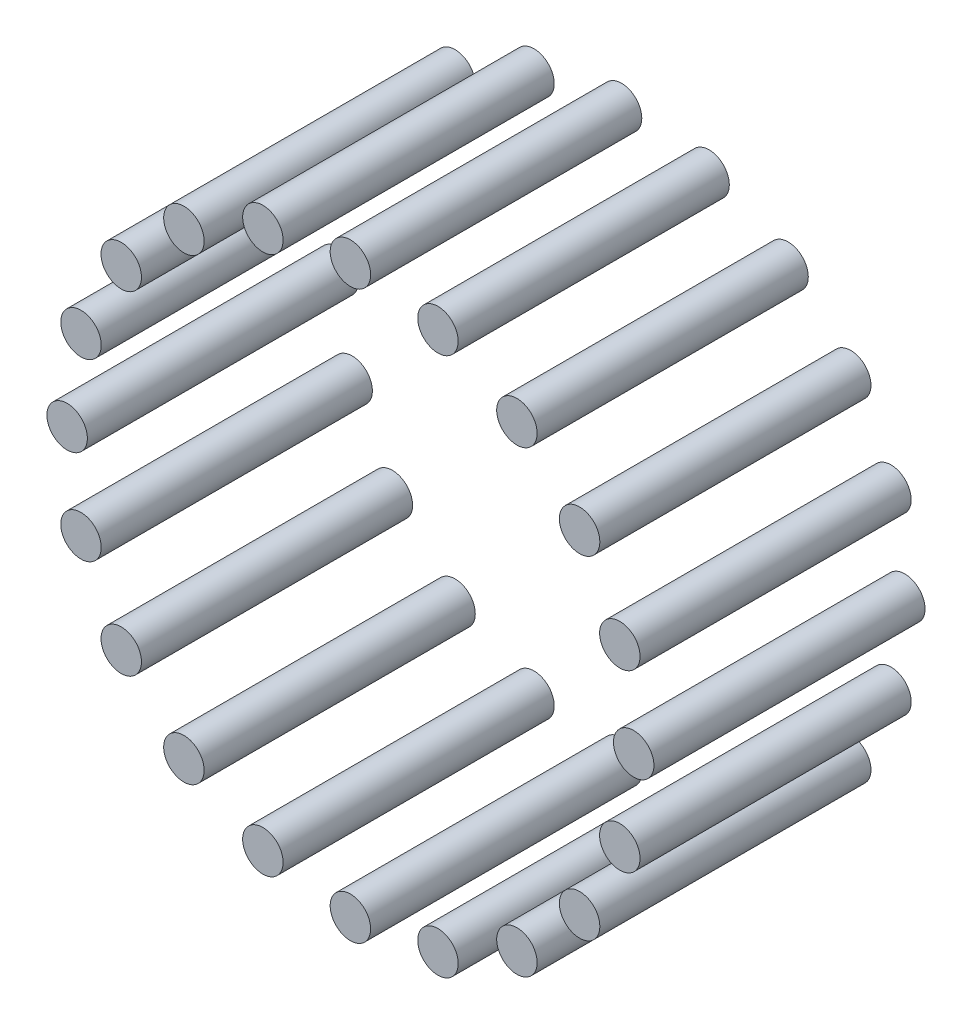
from build123d import *

# Parameters (mm, degrees)
SKETCH1_R              = 2.5
BOSS_EXTRUDE1_DEPTH    = 33.5
BOSS_EXTRUDE1_2_DEPTH  = 33.5
BOSS_EXTRUDE1_3_DEPTH  = 33.5
BOSS_EXTRUDE1_4_DEPTH  = 33.5
BOSS_EXTRUDE1_5_DEPTH  = 33.5
BOSS_EXTRUDE1_6_DEPTH  = 33.5
BOSS_EXTRUDE1_7_DEPTH  = 33.5
BOSS_EXTRUDE1_8_DEPTH  = 33.5
BOSS_EXTRUDE1_9_DEPTH  = 33.5
BOSS_EXTRUDE1_10_DEPTH = 33.5
BOSS_EXTRUDE1_11_DEPTH = 33.5
BOSS_EXTRUDE1_12_DEPTH = 33.5
BOSS_EXTRUDE1_13_DEPTH = 33.5
BOSS_EXTRUDE1_14_DEPTH = 33.5
BOSS_EXTRUDE1_15_DEPTH = 33.5
BOSS_EXTRUDE1_16_DEPTH = 33.5
BOSS_EXTRUDE1_17_DEPTH = 33.5
BOSS_EXTRUDE1_18_DEPTH = 33.5
BOSS_EXTRUDE1_19_DEPTH = 33.5
BOSS_EXTRUDE1_20_DEPTH = 33.5


with BuildPart() as part:
    # Sketch1 → Boss-Extrude1 (new body)
    with BuildSketch(Plane.XY):
        with Locations((0, 35)):
            Circle(SKETCH1_R)
    extrude(amount=BOSS_EXTRUDE1_DEPTH)


with BuildPart() as body_2:
    # Sketch1 → Boss-Extrude1 2 (new body)
    with BuildSketch(Plane.XY):
        with Locations((10.815594803, 33.28697807)):
            Circle(SKETCH1_R)
    extrude(amount=BOSS_EXTRUDE1_2_DEPTH)


with BuildPart() as body_3:
    # Sketch1 → Boss-Extrude1 3 (new body)
    with BuildSketch(Plane.XY):
        with Locations((20.57248383, 28.315594803)):
            Circle(SKETCH1_R)
    extrude(amount=BOSS_EXTRUDE1_3_DEPTH)


with BuildPart() as body_4:
    # Sketch1 → Boss-Extrude1 4 (new body)
    with BuildSketch(Plane.XY):
        with Locations((28.315594803, 20.57248383)):
            Circle(SKETCH1_R)
    extrude(amount=BOSS_EXTRUDE1_4_DEPTH)


with BuildPart() as body_5:
    # Sketch1 → Boss-Extrude1 5 (new body)
    with BuildSketch(Plane.XY):
        with Locations((33.28697807, 10.815594803)):
            Circle(SKETCH1_R)
    extrude(amount=BOSS_EXTRUDE1_5_DEPTH)


with BuildPart() as body_6:
    # Sketch1 → Boss-Extrude1 6 (new body)
    with BuildSketch(Plane.XY):
        with Locations((35, 0)):
            Circle(SKETCH1_R)
    extrude(amount=BOSS_EXTRUDE1_6_DEPTH)


with BuildPart() as body_7:
    # Sketch1 → Boss-Extrude1 7 (new body)
    with BuildSketch(Plane.XY):
        with Locations((33.28697807, -10.815594803)):
            Circle(SKETCH1_R)
    extrude(amount=BOSS_EXTRUDE1_7_DEPTH)


with BuildPart() as body_8:
    # Sketch1 → Boss-Extrude1 8 (new body)
    with BuildSketch(Plane.XY):
        with Locations((28.315594803, -20.57248383)):
            Circle(SKETCH1_R)
    extrude(amount=BOSS_EXTRUDE1_8_DEPTH)


with BuildPart() as body_9:
    # Sketch1 → Boss-Extrude1 9 (new body)
    with BuildSketch(Plane.XY):
        with Locations((20.57248383, -28.315594803)):
            Circle(SKETCH1_R)
    extrude(amount=BOSS_EXTRUDE1_9_DEPTH)


with BuildPart() as body_10:
    # Sketch1 → Boss-Extrude1 10 (new body)
    with BuildSketch(Plane.XY):
        with Locations((10.815594803, -33.28697807)):
            Circle(SKETCH1_R)
    extrude(amount=BOSS_EXTRUDE1_10_DEPTH)


with BuildPart() as body_11:
    # Sketch1 → Boss-Extrude1 11 (new body)
    with BuildSketch(Plane.XY):
        with Locations((0, -35)):
            Circle(SKETCH1_R)
    extrude(amount=BOSS_EXTRUDE1_11_DEPTH)


with BuildPart() as body_12:
    # Sketch1 → Boss-Extrude1 12 (new body)
    with BuildSketch(Plane.XY):
        with Locations((-10.815594803, -33.28697807)):
            Circle(SKETCH1_R)
    extrude(amount=BOSS_EXTRUDE1_12_DEPTH)


with BuildPart() as body_13:
    # Sketch1 → Boss-Extrude1 13 (new body)
    with BuildSketch(Plane.XY):
        with Locations((-20.57248383, -28.315594803)):
            Circle(SKETCH1_R)
    extrude(amount=BOSS_EXTRUDE1_13_DEPTH)


with BuildPart() as body_14:
    # Sketch1 → Boss-Extrude1 14 (new body)
    with BuildSketch(Plane.XY):
        with Locations((-28.315594803, -20.57248383)):
            Circle(SKETCH1_R)
    extrude(amount=BOSS_EXTRUDE1_14_DEPTH)


with BuildPart() as body_15:
    # Sketch1 → Boss-Extrude1 15 (new body)
    with BuildSketch(Plane.XY):
        with Locations((-33.28697807, -10.815594803)):
            Circle(SKETCH1_R)
    extrude(amount=BOSS_EXTRUDE1_15_DEPTH)


with BuildPart() as body_16:
    # Sketch1 → Boss-Extrude1 16 (new body)
    with BuildSketch(Plane.XY):
        with Locations((-35, 0)):
            Circle(SKETCH1_R)
    extrude(amount=BOSS_EXTRUDE1_16_DEPTH)


with BuildPart() as body_17:
    # Sketch1 → Boss-Extrude1 17 (new body)
    with BuildSketch(Plane.XY):
        with Locations((-33.28697807, 10.815594803)):
            Circle(SKETCH1_R)
    extrude(amount=BOSS_EXTRUDE1_17_DEPTH)


with BuildPart() as body_18:
    # Sketch1 → Boss-Extrude1 18 (new body)
    with BuildSketch(Plane.XY):
        with Locations((-28.315594803, 20.57248383)):
            Circle(SKETCH1_R)
    extrude(amount=BOSS_EXTRUDE1_18_DEPTH)


with BuildPart() as body_19:
    # Sketch1 → Boss-Extrude1 19 (new body)
    with BuildSketch(Plane.XY):
        with Locations((-20.57248383, 28.315594803)):
            Circle(SKETCH1_R)
    extrude(amount=BOSS_EXTRUDE1_19_DEPTH)


with BuildPart() as body_20:
    # Sketch1 → Boss-Extrude1 20 (new body)
    with BuildSketch(Plane.XY):
        with Locations((-10.815594803, 33.28697807)):
            Circle(SKETCH1_R)
    extrude(amount=BOSS_EXTRUDE1_20_DEPTH)


solid = Compound([part.part, body_2.part, body_3.part, body_4.part, body_5.part, body_6.part, body_7.part, body_8.part, body_9.part, body_10.part, body_11.part, body_12.part, body_13.part, body_14.part, body_15.part, body_16.part, body_17.part, body_18.part, body_19.part, body_20.part])
